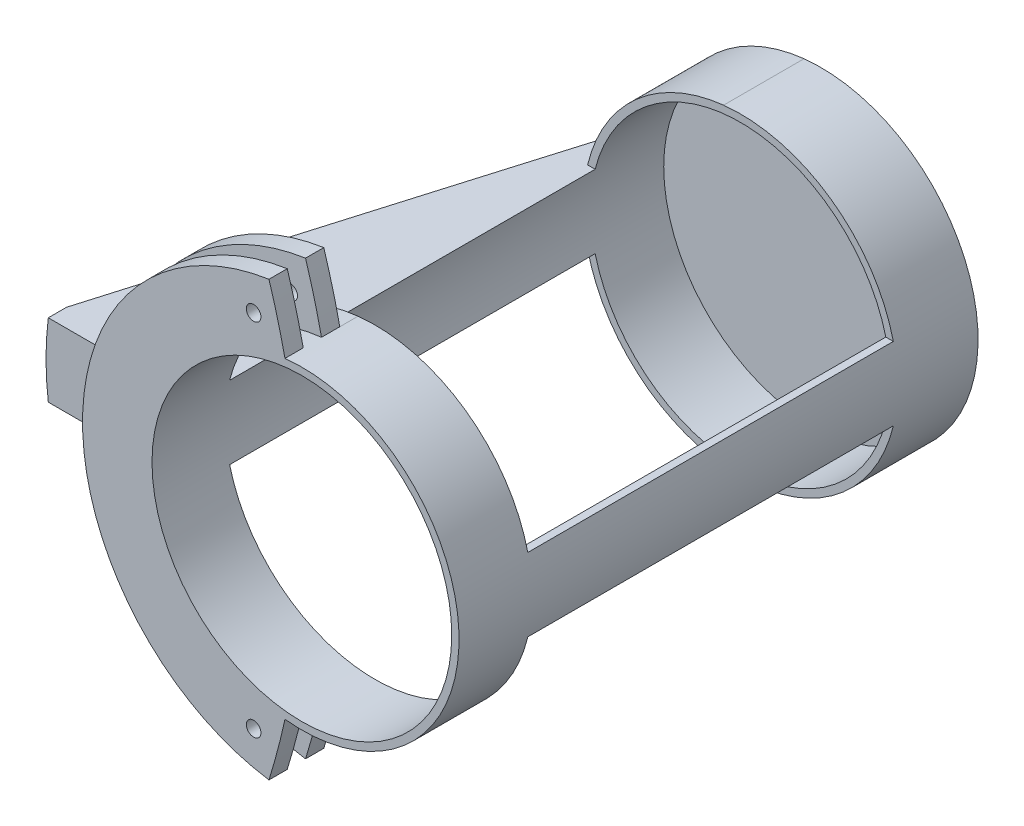
from build123d import *
from build123d.topology import SkipClean

# Parameters (mm, degrees)
SKETCH1_R           = 43
BOSS_EXTRUDE1_DEPTH = 2
SKETCH2_R           = 43
SKETCH2_R_2         = 41
BOSS_EXTRUDE2_DEPTH = 20
BOSS_EXTRUDE3_DEPTH = 100
SKETCH4_R           = 43
SKETCH4_R_2         = 41
BOSS_EXTRUDE4_DEPTH = 20
BOSS_EXTRUDE5_DEPTH = 5
BOSS_EXTRUDE6_DEPTH = 127
SKETCH7_W           = 7.682690019
SKETCH7_H           = 127
BOSS_EXTRUDE7_DEPTH = 5
SKETCH10_R          = 2
CUT_EXTRUDE2_DEPTH  = 15


with BuildPart() as part:
    # Sketch1 → Boss-Extrude1 (new body)
    with BuildSketch(Plane.XY):
        Circle(SKETCH1_R)
    extrude(amount=BOSS_EXTRUDE1_DEPTH)

    # Sketch2 → Boss-Extrude2 (add)
    with BuildSketch(Plane.XY.offset(2)):
        Circle(SKETCH2_R)
        Circle(SKETCH2_R_2, mode=Mode.SUBTRACT)
    extrude(amount=BOSS_EXTRUDE2_DEPTH)

    # Sketch3 → Boss-Extrude3 (add)
    with SkipClean():  # the faces are left unmerged after this step: merging them gives an invalid solid
        with BuildSketch(Plane.XY.offset(22)):
            with BuildLine():
                Line((39.761790704, 10), (41.821047333, 10))
                ThreePointArc((41.821047333, 10), (43, 0), (41.821047333, -10))
                Line((41.821047333, -10), (39.761790704, -10))
                ThreePointArc((39.761790704, -10), (41, 0), (39.761790704, 10))
            make_face()
            with BuildLine():
                Line((-41.821047333, -10), (-39.761790704, -10))
                ThreePointArc((-39.761790704, -10), (-41, 0), (-39.761790704, 10))
                Line((-39.761790704, 10), (-41.821047333, 10))
                ThreePointArc((-41.821047333, 10), (-43, 0), (-41.821047333, -10))
            make_face()
        extrude(amount=BOSS_EXTRUDE3_DEPTH)

    # Sketch4 → Boss-Extrude4 (add)
    with SkipClean():  # the faces are left unmerged after this step: merging them gives an invalid solid
        with BuildSketch(Plane.XY.offset(122)):
            Circle(SKETCH4_R)
            Circle(SKETCH4_R_2, mode=Mode.SUBTRACT)
        extrude(amount=BOSS_EXTRUDE4_DEPTH)

    # Sketch5 → Boss-Extrude5 (add)
    with SkipClean():  # the faces are left unmerged after this step: merging them gives an invalid solid
        with BuildSketch(Plane.XY.offset(142)):
            with BuildLine():
                ThreePointArc((-4.6225, 42.750818633), (-6.633671033, 51.082901463), (-9, 59.3211598))
                ThreePointArc((-9, 59.3211598), (-60, 0), (-9, -59.3211598))
                ThreePointArc((-9, -59.3211598), (-6.633671033, -51.082901463), (-4.6225, -42.750818633))
                ThreePointArc((-4.6225, -42.750818633), (-43, 0), (-4.6225, 42.750818633))
            make_face()
        boss_extrude5 = extrude(amount=-BOSS_EXTRUDE5_DEPTH)

    # Mirror1: Boss-Extrude5 across plane
    with SkipClean():  # the faces are left unmerged after this step: merging them gives an invalid solid
        add(boss_extrude5.mirror(Plane(origin=(0, 0, 134.5), x_dir=(1, 0, 0), z_dir=(0, 0, -1))))

    # Sketch6 → Boss-Extrude6 (add)
    with SkipClean():  # the faces are left unmerged after this step: merging them gives an invalid solid
        with BuildSketch(Plane(origin=(0, 0, 127), x_dir=(-1, 0, 0), z_dir=(0, 0, -1))):
            with BuildLine():
                ThreePointArc((43, 0), (42.704244726, -5.034628323), (41.821047333, -10))
                Line((41.821047333, -10), (59.160797831, -10))
                ThreePointArc((59.160797831, -10), (59.789831367, -5.017575617), (60, 0))
                ThreePointArc((60, 0), (59.789831367, 5.017575617), (59.160797831, 10))
                Line((59.160797831, 10), (41.821047333, 10))
                ThreePointArc((41.821047333, 10), (42.704244726, 5.034628323), (43, 0))
            make_face()
            with BuildLine():
                ThreePointArc((60, 0), (59.789831367, -5.017575617), (59.160797831, -10))
                Line((59.160797831, -10), (80, -10))
                Line((80, -10), (80, 10))
                Line((80, 10), (59.160797831, 10))
                ThreePointArc((59.160797831, 10), (59.789831367, 5.017575617), (60, 0))
            make_face()
        extrude(amount=BOSS_EXTRUDE6_DEPTH)

    # Sketch7 → Cut-Revolve1 (revolve, cut)
    with SkipClean():  # the faces are left unmerged after this step: merging them gives an invalid solid
        with BuildSketch(Plane(origin=(0, 0, 0), x_dir=(1, 0, 0), z_dir=(0, 1, 0)), mode=Mode.PRIVATE) as cut_revolve1_sk:
            with Locations((-83.84134501, -63.5)):
                Rectangle(SKETCH7_W, SKETCH7_H)
            Polygon((-80, 0), (-80, -127), (-43, 0), align=None)
        revolve(cut_revolve1_sk.sketch.rotate(Axis((0, 0, -46.383399508), (0, 0, 1)), 276.171221478), axis=Axis((0, 0, -46.383399508), (0, 0, 1)), mode=Mode.SUBTRACT)

    # Sketch8 → Boss-Extrude7 (add)
    with SkipClean():  # the faces are left unmerged after this step: merging them gives an invalid solid
        with BuildSketch(Plane.XY.offset(127)):
            with BuildLine():
                Line((-59.160797831, 10), (-79.372539332, 10))
                ThreePointArc((-79.372539332, 10), (-80, 0), (-79.372539332, -10))
                Line((-79.372539332, -10), (-59.160797831, -10))
                ThreePointArc((-59.160797831, -10), (-60, 0), (-59.160797831, 10))
            make_face()
        extrude(amount=BOSS_EXTRUDE7_DEPTH)

    # Sketch10 → Cut-Extrude2 (cut)
    with SkipClean():  # the faces are left unmerged after this step: merging them gives an invalid solid
        with BuildSketch(Plane.XY.offset(142)):
            with Locations((-13.1997713, 49.262217141)):
                Circle(SKETCH10_R)
            with Locations((-13.1997713, -49.262217141)):
                Circle(SKETCH10_R)
        extrude(amount=-CUT_EXTRUDE2_DEPTH, mode=Mode.SUBTRACT)


solid = part.part
